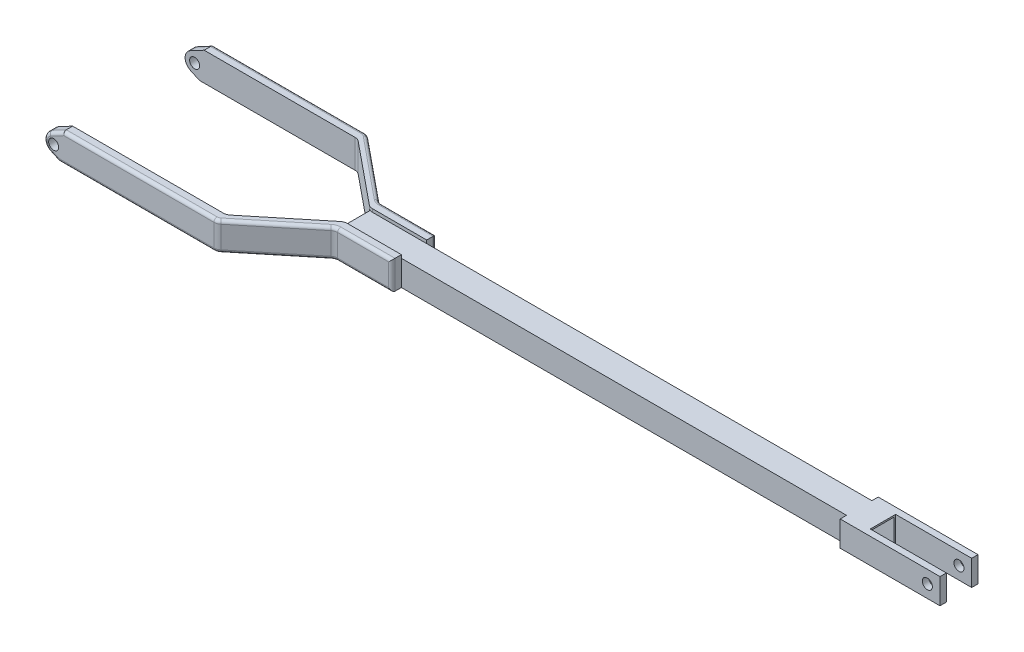
from build123d import *

# Parameters (mm, degrees)
SKETCH1_W                = 332
SKETCH1_H                = 16
BOSS_EXTRUDE1_DEPTH      = 8
SHELL1_T                 = -1
SKETCH2_W                = 4
SKETCH2_H                = 16
BOSS_EXTRUDE2_DEPTH      = 48
BOSS_EXTRUDE2_DEPTH_BACK = 15
BOSS_EXTRUDE3_START      = -16
BOSS_EXTRUDE3_DEPTH      = 18
CUT_EXTRUDE1_DEPTH       = 40
FILLET1_R                = 5
FILLET2_R                = 2
FILLET1_OF_MIRROR1_R     = 5
FILLET2_OF_MIRROR1_R     = 2
SKETCH1_3_R              = 3.175
CUT_EXTRUDE2_DEPTH       = 48.5
CUT_EXTRUDE2_DEPTH_BACK  = 48.5


with BuildPart() as part:
    # Sketch1 → Boss-Extrude1 (new body, symmetric)
    with BuildSketch(Plane.XY):
        with Locations((-206, 0)):
            Rectangle(SKETCH1_W, SKETCH1_H)
    extrude(amount=BOSS_EXTRUDE1_DEPTH, both=True)

    # Shell1
    shell1_openings = [part.faces().sort_by_distance(p)[0] for p in [
        (-40, 0, 0),
        (-372, 0, 0),
    ]]
    offset(amount=SHELL1_T, openings=shell1_openings, kind=Kind.INTERSECTION)

    # Sketch2 → Boss-Extrude2 (add, two sides)
    with BuildSketch(Plane(origin=(-40, 0, 0), x_dir=(0, 0, -1), z_dir=(1, 0, 0))) as boss_extrude2_sk:
        with Locations((-10, 0)):
            Rectangle(SKETCH2_W, SKETCH2_H)
        with Locations((10, 0)):
            Rectangle(SKETCH2_W, SKETCH2_H)
    extrude(amount=BOSS_EXTRUDE2_DEPTH)
    extrude(boss_extrude2_sk.sketch, amount=-BOSS_EXTRUDE2_DEPTH_BACK)

    # Sketch3 → Boss-Extrude3 (add)
    with BuildSketch(Plane(origin=(0, 8, 0), x_dir=(1, 0, 0), z_dir=(0, 1, 0)).offset(BOSS_EXTRUDE3_START)):
        Polygon((-336, -14), (-336, -8), (-372, -8), (-413, -41.5), (-522, -41.5), (-522, -47.5), (-413, -47.5), (-372, -14), align=None)
    boss_extrude3 = extrude(amount=BOSS_EXTRUDE3_DEPTH)

    # Sketch4 → Cut-Extrude1 (cut)
    with BuildSketch(Plane.XY.offset(47.5)):
        with BuildLine():
            Line((-510, 10), (-518.823529412, 5.294117647))
            ThreePointArc((-518.823529412, 5.294117647), (-521.99760764, -0.169418391), (-518.520172623, -5.445064733))
            Line((-518.520172623, -5.445064733), (-513, -8))
            Line((-513, -8), (-540.277730866, -26.369352849))
            Line((-540.277730866, -26.369352849), (-542.314823198, 28.070412495))
            Line((-542.314823198, 28.070412495), (-510, 10))
        make_face()
    cut_extrude1 = extrude(amount=-CUT_EXTRUDE1_DEPTH, mode=Mode.SUBTRACT)

    # Fillet1
    fillet1_edges = [part.edges().sort_by_distance(p)[0] for p in [
        (-413, 1, 41.5),
        (-413, 1, 47.5),
        (-372, 1, 14),
        (-372, 9, 8),
    ]]
    fillet(fillet1_edges, radius=FILLET1_R)

    # Fillet2
    fillet2_edges = [part.edges().sort_by_distance(p)[0] for p in [
        (-462.391472159, 10, 47.5),
        (-392.5, 10, 30.75),
        (-413.103576447, 10, 47.209535386),
        (-353.108527841, -8, 14),
        (-392.5, -8, 30.75),
        (-413.103576447, -8, 47.209535386),
        (-371.896423553, -8, 14.290464614),
        (-371.896423553, 10, 14.290464614),
        (-353.108527841, 10, 14),
        (-336, 1, 14),
        (-463.891472159, -8, 47.5),
        (-521.99760764, -0.169418391, 47.5),
        (-514.411764706, 7.647058824, 47.5),
        (-515.760086311, -6.722532367, 47.5),
    ]]
    fillet(fillet2_edges, radius=FILLET2_R)

    # Mirror1: Boss-Extrude3, Cut-Extrude1 across plane
    add(boss_extrude3.mirror(Plane.XY))
    add(cut_extrude1.mirror(Plane.XY), mode=Mode.SUBTRACT)

    # Fillet1 of Mirror1
    fillet1_of_mirror1_edges = [part.edges().sort_by_distance(p)[0] for p in [
        (-413, 1, -41.5),
        (-413, 1, -47.5),
        (-372, 1, -14),
        (-372, 9, -8),
    ]]
    fillet(fillet1_of_mirror1_edges, radius=FILLET1_OF_MIRROR1_R)

    # Fillet2 of Mirror1
    fillet2_of_mirror1_edges = [part.edges().sort_by_distance(p)[0] for p in [
        (-462.391472159, 10, -47.5),
        (-392.5, 10, -30.75),
        (-413.103576447, 10, -47.209535386),
        (-353.108527841, -8, -14),
        (-392.5, -8, -30.75),
        (-413.103576447, -8, -47.209535386),
        (-371.896423553, -8, -14.290464614),
        (-371.896423553, 10, -14.290464614),
        (-353.108527841, 10, -14),
        (-336, 1, -14),
        (-463.891472159, -8, -47.5),
        (-521.99760764, -0.169418391, -47.5),
        (-514.411764706, 7.647058824, -47.5),
        (-515.760086311, -6.722532367, -47.5),
    ]]
    fillet(fillet2_of_mirror1_edges, radius=FILLET2_OF_MIRROR1_R)

    # Sketch1_3 → Cut-Extrude2 (cut, two sides)
    with BuildSketch(Plane.XY) as cut_extrude2_sk:
        with Locations((-516, 0)):
            Circle(SKETCH1_3_R)
        Circle(SKETCH1_3_R)
    extrude(amount=CUT_EXTRUDE2_DEPTH, mode=Mode.SUBTRACT)
    extrude(cut_extrude2_sk.sketch, amount=-CUT_EXTRUDE2_DEPTH_BACK, mode=Mode.SUBTRACT)


solid = part.part
